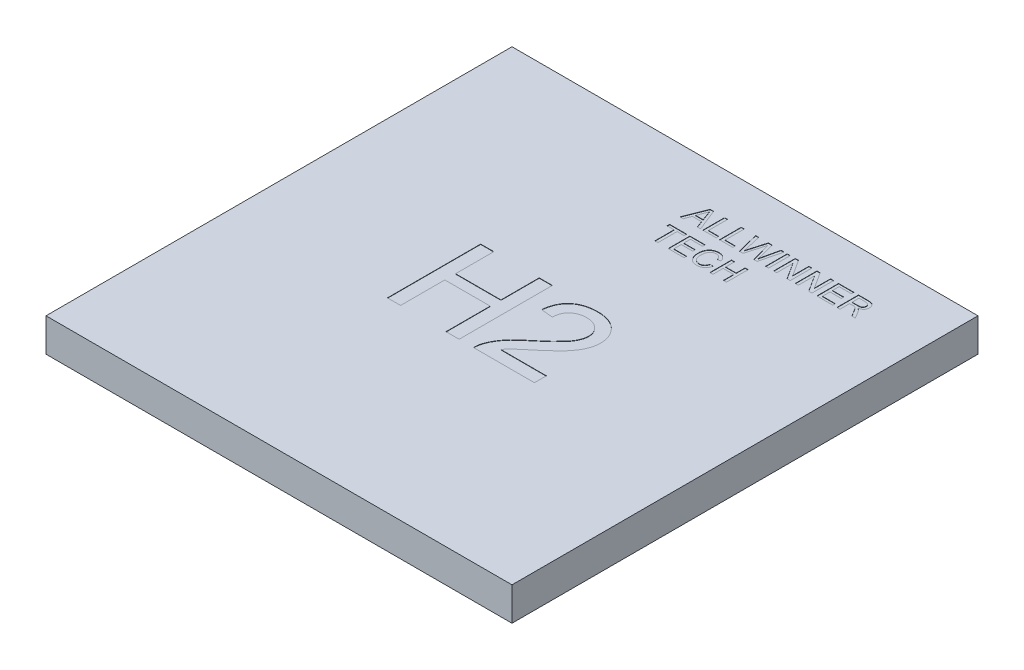
from build123d import *

# Parameters (mm, degrees)
SKETCH_1_W          = 14
SKETCH_1_H          = 14
EXTRUDE_1_DEPTH     = 1
SKETCH_2_W          = 0.091666667
SKETCH_2_H          = 0.65
CUT_EXTRUDE_1_DEPTH = 0.01


with BuildPart() as part:
    # Эскиз1 → Бобышка-Вытянуть1 (new body)
    with BuildSketch(Plane(origin=(0, 0, 0), x_dir=(1, 0, 0), z_dir=(0, 1, 0))):
        Rectangle(SKETCH_1_W, SKETCH_1_H)
    extrude(amount=EXTRUDE_1_DEPTH)

    # Эскиз2 → Вырез-Вытянуть1 (cut)
    with BuildSketch(Plane(origin=(0, 1, 0), x_dir=(1, 0, 0), z_dir=(0, 1, 0))):
        Polygon((-0.049679802, 5.096192526), (0.208393115, 5.746192526), (0.311778531, 5.746192526), (0.569851448, 5.096192526), (0.472585823, 5.096192526), (0.39862749, 5.296192526), (0.121544156, 5.296192526), (0.047585823, 5.096192526), align=None)
        with BuildLine():
            Line((0.149148323, 5.371192526), (0.371023323, 5.371192526))
            Line((0.371023323, 5.371192526), (0.307872281, 5.542025859))
            add(Edge.make_bspline(
                [(0.307872281, 5.542025859), (0.305451296, 5.548626626), (0.300717812, 5.561532372), (0.293658762, 5.580283332), (0.287209727, 5.598090013), (0.280885919, 5.614697093), (0.275177305, 5.630345806), (0.269915528, 5.644930453), (0.264711676, 5.658349663), (0.261588771, 5.667019856), (0.260085823, 5.671192526)],
                knots=[0, 0, 0, 0, 1.225184869, 2.395467751, 3.491410812, 4.525364584, 5.492066482, 6.394148129, 7.227157926, 8, 8, 8, 8], degree=3))
            add(Edge.make_bspline(
                [(0.260085823, 5.671192526), (0.257599656, 5.660903089), (0.252617072, 5.640281791), (0.242184753, 5.610068821), (0.230250543, 5.580132164), (0.220558542, 5.560841186), (0.215684781, 5.551140442)],
                knots=[0, 0, 0, 0, 0.9891762, 1.982431084, 2.985436691, 4, 4, 4, 4], degree=3))
            Line((0.215684781, 5.551140442), (0.149148323, 5.371192526))
        make_face(mode=Mode.SUBTRACT)
        Polygon((0.63925249, 5.096192526), (0.63925249, 5.746192526), (0.730919156, 5.746192526), (0.730919156, 5.171192526), (1.03925249, 5.171192526), (1.03925249, 5.096192526), align=None)
        Polygon((1.13925249, 5.096192526), (1.13925249, 5.746192526), (1.230919156, 5.746192526), (1.230919156, 5.171192526), (1.53925249, 5.171192526), (1.53925249, 5.096192526), align=None)
        with BuildLine():
            Line((1.736257698, 5.096192526), (1.572585823, 5.746192526))
            Line((1.572585823, 5.746192526), (1.667247281, 5.746192526))
            Line((1.667247281, 5.746192526), (1.763731656, 5.318718567))
            add(Edge.make_bspline(
                [(1.763731656, 5.318718567), (1.768732077, 5.296672008), (1.778681867, 5.252803968), (1.788523558, 5.20891155), (1.793419156, 5.187077942)],
                knots=[0, 0, 0, 0, 1.00513078, 2, 2, 2, 2], degree=3))
            add(Edge.make_bspline(
                [(1.793419156, 5.187077942), (1.795737068, 5.194928767), (1.800112864, 5.209749694), (1.806028091, 5.230759787), (1.811400702, 5.249096811), (1.815977892, 5.264846252), (1.819684024, 5.278030236), (1.822883857, 5.28848676), (1.825064823, 5.296420596), (1.826357267, 5.300794547), (1.826882698, 5.302572734)],
                knots=[0, 0, 0, 0, 1.633809233, 3.084334118, 4.356383392, 5.447555203, 6.357852567, 7.089694452, 7.629924063, 8, 8, 8, 8], degree=3))
            Line((1.826882698, 5.302572734), (1.955268115, 5.746192526))
            Line((1.955268115, 5.746192526), (2.065554573, 5.746192526))
            Line((2.065554573, 5.746192526), (2.158393115, 5.420541484))
            add(Edge.make_bspline(
                [(2.158393115, 5.420541484), (2.163516509, 5.40042404), (2.173618735, 5.360756794), (2.187041172, 5.301670961), (2.199429653, 5.244018563), (2.20656565, 5.205887779), (2.210085823, 5.187077942)],
                knots=[0, 0, 0, 0, 1.04154457, 2.053700482, 3.039894486, 4, 4, 4, 4], degree=3))
            add(Edge.make_bspline(
                [(2.210085823, 5.187077942), (2.212243963, 5.196716074), (2.216785556, 5.216998567), (2.224201709, 5.248938702), (2.231877116, 5.284058513), (2.237412503, 5.308479343), (2.240294156, 5.321192526)],
                knots=[0, 0, 0, 0, 0.862130727, 1.814268567, 2.86213528, 4, 4, 4, 4], degree=3))
            Line((2.240294156, 5.321192526), (2.336257698, 5.746192526))
            Line((2.336257698, 5.746192526), (2.430919156, 5.746192526))
            Line((2.430919156, 5.746192526), (2.267117073, 5.096192526))
            Line((2.267117073, 5.096192526), (2.166335823, 5.096192526))
            Line((2.166335823, 5.096192526), (2.030528531, 5.592937317))
            add(Edge.make_bspline(
                [(2.030528531, 5.592937317), (2.02916483, 5.597793459), (2.026574307, 5.607018321), (2.023178737, 5.620182511), (2.019811452, 5.631759874), (2.01713311, 5.64190003), (2.014815229, 5.650500796), (2.012762646, 5.657536991), (2.011442479, 5.663146325), (2.010487796, 5.666334503), (2.010085823, 5.667676901)],
                knots=[0, 0, 0, 0, 1.562239628, 2.967673567, 4.210417925, 5.296319877, 6.215971374, 6.969386481, 7.566055473, 8, 8, 8, 8], degree=3))
            add(Edge.make_bspline(
                [(2.010085823, 5.667676901), (2.00767561, 5.659164066), (2.003121493, 5.643078992), (1.996377055, 5.620434574), (1.990717764, 5.600523267), (1.987131341, 5.588204797), (1.985476448, 5.582520651)],
                knots=[0, 0, 0, 0, 1.197730334, 2.263121701, 3.198547257, 4, 4, 4, 4], degree=3))
            Line((1.985476448, 5.582520651), (1.84472124, 5.096192526))
            Line((1.84472124, 5.096192526), (1.736257698, 5.096192526))
        make_face()
        with Locations((2.568419157, 5.421192526)):
            Rectangle(SKETCH_2_W, SKETCH_2_H)
        Polygon((2.76425249, 5.096192526), (2.76425249, 5.746192526), (2.86112749, 5.746192526), (3.172585823, 5.261166484), (3.172585823, 5.746192526), (3.26425249, 5.746192526), (3.26425249, 5.096192526), (3.16737749, 5.096192526), (2.855919156, 5.581218567), (2.855919156, 5.096192526), align=None)
        Polygon((3.41425249, 5.096192526), (3.41425249, 5.746192526), (3.51112749, 5.746192526), (3.822585823, 5.261166484), (3.822585823, 5.746192526), (3.91425249, 5.746192526), (3.91425249, 5.096192526), (3.81737749, 5.096192526), (3.505919156, 5.581218567), (3.505919156, 5.096192526), align=None)
        Polygon((4.06425249, 5.096192526), (4.06425249, 5.746192526), (4.522585823, 5.746192526), (4.522585823, 5.671192526), (4.155919156, 5.671192526), (4.155919156, 5.471192526), (4.497585823, 5.471192526), (4.497585823, 5.396192526), (4.155919156, 5.396192526), (4.155919156, 5.171192526), (4.53925249, 5.171192526), (4.53925249, 5.096192526), align=None)
        with BuildLine():
            Line((4.66425249, 5.096192526), (4.66425249, 5.746192526))
            Line((4.66425249, 5.746192526), (4.94628374, 5.746192526))
            add(Edge.make_bspline(
                [(4.94628374, 5.746192526), (4.952924712, 5.746140491), (4.965777537, 5.746039784), (4.984416786, 5.745326891), (5.001814657, 5.743790081), (5.018003138, 5.742128236), (5.032979354, 5.739577526), (5.046727852, 5.736651919), (5.059269861, 5.733170402), (5.070661451, 5.729058462), (5.081230362, 5.724406418), (5.091026944, 5.718666547), (5.100458429, 5.712376872), (5.109174781, 5.704987442), (5.117405895, 5.696896701), (5.125144142, 5.687994712), (5.132274963, 5.678204224), (5.141069977, 5.664192006), (5.150505234, 5.645530681), (5.158366285, 5.621648229), (5.16343495, 5.596666313), (5.163977311, 5.579594067), (5.16425249, 5.570932109)],
                knots=[0, 0, 0, 0, 1.242255013, 2.404239178, 3.487702428, 4.508875116, 5.447164253, 6.327763259, 7.137389581, 7.87956647, 8.591787438, 9.293660819, 10.000726923, 10.709654955, 11.427269343, 12.158170644, 12.913245971, 13.690346794, 15.251572448, 16.809945773, 18.381459854, 20, 20, 20, 20], degree=3))
            add(Edge.make_bspline(
                [(5.16425249, 5.570932109), (5.164125296, 5.565371904), (5.16387408, 5.554390119), (5.161949737, 5.538243956), (5.158467796, 5.522816946), (5.154002892, 5.507973982), (5.147891801, 5.493925366), (5.140812367, 5.480384151), (5.132041955, 5.467722349), (5.122222508, 5.455602797), (5.110962237, 5.444285064), (5.098162083, 5.434177466), (5.083948933, 5.425085661), (5.068255848, 5.417260496), (5.051263471, 5.410107924), (5.032758595, 5.404348328), (5.012815903, 5.399645176), (4.998990702, 5.397367728), (4.991856656, 5.396192526)],
                knots=[0, 0, 0, 0, 0.982609109, 1.940720374, 2.867584677, 3.775009516, 4.675469332, 5.571146231, 6.471115823, 7.392408543, 8.32534739, 9.286126426, 10.269214477, 11.301811357, 12.381622301, 13.524260118, 14.722474812, 16, 16, 16, 16], degree=3))
            add(Edge.make_bspline(
                [(4.991856656, 5.396192526), (4.997089749, 5.393548882), (5.007027581, 5.388528509), (5.020786633, 5.380656607), (5.032449705, 5.372613462), (5.039206714, 5.366860769), (5.04237749, 5.364161276)],
                knots=[0, 0, 0, 0, 1.172304973, 2.226249348, 3.167654437, 4, 4, 4, 4], degree=3))
            add(Edge.make_bspline(
                [(5.04237749, 5.364161276), (5.048517877, 5.358141902), (5.061130668, 5.345777681), (5.078511641, 5.32471779), (5.095363092, 5.301274901), (5.10560162, 5.284332645), (5.110867073, 5.275619609)],
                knots=[0, 0, 0, 0, 0.918110279, 1.885863737, 2.912745394, 4, 4, 4, 4], degree=3))
            Line((5.110867073, 5.275619609), (5.217507698, 5.096192526))
            Line((5.217507698, 5.096192526), (5.112429573, 5.096192526))
            Line((5.112429573, 5.096192526), (5.03143999, 5.233432109))
            add(Edge.make_bspline(
                [(5.03143999, 5.233432109), (5.028528011, 5.238247325), (5.022885075, 5.247578422), (5.014734055, 5.261206041), (5.006742248, 5.273752435), (4.999329985, 5.285576188), (4.992196461, 5.296462644), (4.985410605, 5.306449623), (4.979159166, 5.315668138), (4.97141595, 5.32640089), (4.962404133, 5.338276779), (4.95188796, 5.350506702), (4.941873446, 5.360257457), (4.929540388, 5.369819109), (4.914264029, 5.378762427), (4.901278835, 5.382871637), (4.894981656, 5.384864401)],
                knots=[0, 0, 0, 0, 1.130940588, 2.191577161, 3.191089816, 4.120344442, 4.99615009, 5.80661983, 6.546979556, 7.234477901, 8.466216387, 9.541989141, 10.473533583, 11.269175393, 12.675684693, 14, 14, 14, 14], degree=3))
            add(Edge.make_bspline(
                [(4.894981656, 5.384864401), (4.892339593, 5.385340854), (4.886307685, 5.386428612), (4.876065519, 5.387139029), (4.863655879, 5.387893041), (4.854662401, 5.387871072), (4.849799365, 5.387859192)],
                knots=[0, 0, 0, 0, 0.709978628, 1.620902492, 2.713552433, 4, 4, 4, 4], degree=3))
            Line((4.849799365, 5.387859192), (4.755919156, 5.387859192))
            Line((4.755919156, 5.387859192), (4.755919156, 5.096192526))
            Line((4.755919156, 5.096192526), (4.66425249, 5.096192526))
        make_face()
        with BuildLine():
            Line((4.755919156, 5.462859192), (4.930007698, 5.462859192))
            add(Edge.make_bspline(
                [(4.930007698, 5.462859192), (4.938737157, 5.462995773), (4.955056061, 5.463251098), (4.977875468, 5.465431302), (4.99732268, 5.468895741), (5.01378214, 5.47394903), (5.027610685, 5.480964673), (5.039637633, 5.489514544), (5.049632178, 5.500224149), (5.057946608, 5.512307658), (5.064409584, 5.525604956), (5.069071667, 5.539571818), (5.072123082, 5.554090862), (5.07243021, 5.563972322), (5.072585823, 5.568978984)],
                knots=[0, 0, 0, 0, 1.546323217, 2.890706218, 4.056530419, 5.041445823, 5.928701482, 6.793137403, 7.641659452, 8.509781392, 9.383301667, 10.251423607, 11.114044887, 12, 12, 12, 12], degree=3))
            add(Edge.make_bspline(
                [(5.072585823, 5.568978984), (5.07246484, 5.572627528), (5.07222787, 5.579773956), (5.070985596, 5.590262927), (5.06857032, 5.600229873), (5.065380955, 5.609727483), (5.061119315, 5.618686191), (5.056056661, 5.627175418), (5.050015352, 5.635148114), (5.043095379, 5.642628564), (5.035149994, 5.649435043), (5.026074495, 5.655307558), (5.015940462, 5.660297929), (5.004736115, 5.664258621), (4.99249675, 5.667426529), (4.979152691, 5.669534037), (4.964764962, 5.671059022), (4.954795101, 5.671147193), (4.949669156, 5.671192526)],
                knots=[0, 0, 0, 0, 0.965208469, 1.890559848, 2.786986821, 3.67262109, 4.535197034, 5.405224191, 6.282113641, 7.175449223, 8.095446547, 9.040936516, 10.026471658, 11.075712529, 12.17809725, 13.364958037, 14.645208957, 16, 16, 16, 16], degree=3))
            Line((4.949669156, 5.671192526), (4.755919156, 5.671192526))
            Line((4.755919156, 5.671192526), (4.755919156, 5.462859192))
        make_face(mode=Mode.SUBTRACT)
        Polygon((0.197585823, 4.096192526), (0.197585823, 4.671192526), (-0.01074751, 4.671192526), (-0.01074751, 4.746192526), (0.497585823, 4.746192526), (0.497585823, 4.671192526), (0.28925249, 4.671192526), (0.28925249, 4.096192526), align=None)
        Polygon((0.597585823, 4.096192526), (0.597585823, 4.746192526), (1.055919156, 4.746192526), (1.055919156, 4.671192526), (0.68925249, 4.671192526), (0.68925249, 4.471192526), (1.030919156, 4.471192526), (1.030919156, 4.396192526), (0.68925249, 4.396192526), (0.68925249, 4.171192526), (1.072585823, 4.171192526), (1.072585823, 4.096192526), align=None)
        with BuildLine():
            Line((1.63925249, 4.325619609), (1.730919156, 4.304265442))
            add(Edge.make_bspline(
                [(1.730919156, 4.304265442), (1.72862265, 4.29567378), (1.7241304, 4.278867423), (1.715248675, 4.254815665), (1.705280028, 4.232244117), (1.693982574, 4.211212235), (1.681232664, 4.191840939), (1.667368119, 4.173881272), (1.651839784, 4.157709865), (1.635217412, 4.142953489), (1.61737158, 4.129938405), (1.598517446, 4.118699641), (1.578746149, 4.109137734), (1.557977779, 4.101274609), (1.536198871, 4.095356933), (1.513521565, 4.091043785), (1.489879736, 4.088387136), (1.473764655, 4.088037381), (1.465554573, 4.087859192)],
                knots=[0, 0, 0, 0, 1.145254194, 2.240259345, 3.299159039, 4.322497661, 5.312016644, 6.284080175, 7.241264552, 8.196044782, 9.144516039, 10.082428046, 11.020306713, 11.970622414, 12.939253955, 13.924100776, 14.94240044, 16, 16, 16, 16], degree=3))
            add(Edge.make_bspline(
                [(1.465554573, 4.087859192), (1.45713087, 4.087981573), (1.440650568, 4.088221003), (1.416507875, 4.090168456), (1.393545804, 4.093546011), (1.371807235, 4.09823864), (1.351218999, 4.104040785), (1.33186647, 4.111340397), (1.313783544, 4.120084806), (1.296819386, 4.13002946), (1.281046049, 4.141327035), (1.26610484, 4.153672639), (1.252358483, 4.167406134), (1.239463268, 4.18220326), (1.227700056, 4.19825921), (1.216636076, 4.215355858), (1.206811355, 4.233794447), (1.197861796, 4.253233124), (1.190006578, 4.273483688), (1.183057457, 4.294146134), (1.17737617, 4.315261635), (1.172484949, 4.336652507), (1.168931714, 4.35849874), (1.166110556, 4.380636421), (1.164559426, 4.403201271), (1.164355314, 4.418369199), (1.16425249, 4.426010234)],
                knots=[0, 0, 0, 0, 1.180702053, 2.309949215, 3.392367133, 4.431746864, 5.425408375, 6.388154007, 7.326956194, 8.237882283, 9.141054626, 10.043899035, 10.951650021, 11.86168169, 12.792564695, 13.739356664, 14.713891418, 15.718426911, 16.737522708, 17.757217648, 18.772674716, 19.801476837, 20.831699174, 21.873853055, 22.928926693, 24, 24, 24, 24], degree=3))
            add(Edge.make_bspline(
                [(1.16425249, 4.426010234), (1.16439955, 4.434259039), (1.164690104, 4.450556594), (1.166330275, 4.474604111), (1.169342675, 4.497812906), (1.173526023, 4.520198246), (1.178819632, 4.54177826), (1.185353999, 4.562563461), (1.193046464, 4.582527256), (1.201873575, 4.601691658), (1.211893979, 4.619842742), (1.222808608, 4.637006311), (1.234877816, 4.652900548), (1.247743771, 4.667829115), (1.261727808, 4.681543435), (1.276787225, 4.694074575), (1.292792097, 4.705536835), (1.309740088, 4.715823803), (1.327409667, 4.724850079), (1.345538384, 4.732889862), (1.364198346, 4.739479557), (1.38324161, 4.744958624), (1.402709175, 4.74932047), (1.422646529, 4.752237249), (1.44303525, 4.754138049), (1.456782918, 4.754395653), (1.463731656, 4.754525859)],
                knots=[0, 0, 0, 0, 1.185634383, 2.342514083, 3.462112933, 4.547331452, 5.613960142, 6.653690668, 7.676612054, 8.686959706, 9.683658101, 10.654407272, 11.607580201, 12.5494388, 13.484601218, 14.419076806, 15.362504069, 16.311442244, 17.265594461, 18.212500624, 19.159571152, 20.107257795, 21.059246075, 22.024387127, 23.001429356, 24, 24, 24, 24], degree=3))
            add(Edge.make_bspline(
                [(1.463731656, 4.754525859), (1.471506359, 4.75437931), (1.486788306, 4.754091252), (1.509211841, 4.751721926), (1.530687733, 4.747753563), (1.551309041, 4.742547446), (1.570861369, 4.735419188), (1.589556991, 4.726944509), (1.607209922, 4.716763208), (1.623957519, 4.705155087), (1.639527154, 4.692098737), (1.65413671, 4.67790607), (1.667190485, 4.662222374), (1.679205487, 4.645427223), (1.689803686, 4.627287724), (1.699374977, 4.607962034), (1.707606009, 4.58730649), (1.712010021, 4.572919332), (1.71425249, 4.565593567)],
                knots=[0, 0, 0, 0, 1.098391872, 2.158997981, 3.181470371, 4.182549255, 5.160268219, 6.118029851, 7.079534476, 8.035645336, 8.993622929, 9.94770573, 10.909620999, 11.872786677, 12.862530088, 13.874594564, 14.917769567, 16, 16, 16, 16], degree=3))
            Line((1.71425249, 4.565593567), (1.622585823, 4.545932109))
            add(Edge.make_bspline(
                [(1.622585823, 4.545932109), (1.620785633, 4.551554257), (1.617262103, 4.562558541), (1.611005732, 4.578241601), (1.60424906, 4.592800605), (1.596831138, 4.606136587), (1.588735888, 4.618252741), (1.580149724, 4.629296321), (1.57086693, 4.639061198), (1.561076324, 4.647772524), (1.550525086, 4.655193741), (1.539460582, 4.66177016), (1.527649516, 4.667211144), (1.515261801, 4.671813092), (1.502181648, 4.675315671), (1.488462323, 4.677779873), (1.474091772, 4.679206033), (1.464299048, 4.679417835), (1.459304573, 4.679525859)],
                knots=[0, 0, 0, 0, 1.235697765, 2.418642872, 3.532555292, 4.594392283, 5.610119701, 6.580908344, 7.519430642, 8.427315627, 9.319973334, 10.216139639, 11.118687699, 12.038725643, 12.980015607, 13.949697744, 14.954307006, 16, 16, 16, 16], degree=3))
            add(Edge.make_bspline(
                [(1.459304573, 4.679525859), (1.453570459, 4.679442663), (1.442293149, 4.67927904), (1.425725424, 4.677488209), (1.409814646, 4.67485049), (1.394679397, 4.670895004), (1.380236855, 4.665963541), (1.366572726, 4.659822997), (1.353570776, 4.652625559), (1.341376113, 4.644328005), (1.330091224, 4.634999959), (1.319409868, 4.625138754), (1.309844868, 4.614284487), (1.301031484, 4.602795066), (1.293226361, 4.590467464), (1.286200442, 4.577469599), (1.279998513, 4.563694942), (1.273237989, 4.544308157), (1.266344729, 4.519338425), (1.260364817, 4.488783567), (1.256555754, 4.457747318), (1.256131804, 4.436871772), (1.255919156, 4.426400859)],
                knots=[0, 0, 0, 0, 0.935256702, 1.839373932, 2.716087708, 3.564631604, 4.388828665, 5.203538865, 6.005592122, 6.810952829, 7.606223804, 8.392839071, 9.180346482, 9.963639178, 10.753404291, 11.558266631, 12.372976832, 13.215232055, 14.905983541, 16.594894834, 18.292041732, 20, 20, 20, 20], degree=3))
            add(Edge.make_bspline(
                [(1.255919156, 4.426400859), (1.256158993, 4.413235437), (1.256624298, 4.387693328), (1.261215717, 4.350678592), (1.268215965, 4.316153806), (1.276664255, 4.289217594), (1.28513874, 4.269348938), (1.291992477, 4.255434631), (1.299815744, 4.242559006), (1.308413949, 4.230648941), (1.317897844, 4.219739178), (1.328135301, 4.209771763), (1.339128606, 4.200650786), (1.351008019, 4.192803216), (1.363316287, 4.185835258), (1.37589809, 4.179639217), (1.388761349, 4.17439888), (1.401957962, 4.17032808), (1.415302613, 4.166810342), (1.428942279, 4.164512391), (1.442873072, 4.1632155), (1.452227255, 4.162978914), (1.456960823, 4.162859192)],
                knots=[0, 0, 0, 0, 2.10686522, 4.087509323, 5.961373225, 7.741398778, 8.594514555, 9.418024779, 10.222433421, 11.003575649, 11.767087398, 12.533660211, 13.289033706, 14.050297079, 14.809623433, 15.552362432, 16.294320901, 17.0305302, 17.761969017, 18.502233515, 19.242073914, 20, 20, 20, 20], degree=3))
            add(Edge.make_bspline(
                [(1.456960823, 4.162859192), (1.462609688, 4.162977661), (1.473768194, 4.163211678), (1.49012798, 4.165260045), (1.505898589, 4.168278582), (1.520888961, 4.172936488), (1.535300734, 4.17863955), (1.549015828, 4.185672421), (1.561991112, 4.194130914), (1.574379202, 4.203734737), (1.585951652, 4.214662247), (1.596557181, 4.226825405), (1.606071538, 4.240279663), (1.614893742, 4.2548091), (1.622306014, 4.270847761), (1.629171528, 4.287917607), (1.634892371, 4.306299195), (1.637778239, 4.319086958), (1.63925249, 4.325619609)],
                knots=[0, 0, 0, 0, 1.013374089, 2.001772144, 2.95501459, 3.891367103, 4.814208647, 5.733921849, 6.652182523, 7.590185968, 8.54346024, 9.504121027, 10.481158517, 11.497760682, 12.549996529, 13.647863555, 14.798406869, 16, 16, 16, 16], degree=3))
        make_face()
        Polygon((1.847585823, 4.096192526), (1.847585823, 4.746192526), (1.93925249, 4.746192526), (1.93925249, 4.479525859), (2.255919156, 4.479525859), (2.255919156, 4.746192526), (2.347585823, 4.746192526), (2.347585823, 4.096192526), (2.255919156, 4.096192526), (2.255919156, 4.404525859), (1.93925249, 4.404525859), (1.93925249, 4.096192526), align=None)
        Polygon((-2.336984878, -1.40444844), (-2.336984878, 1.39555156), (-1.942113084, 1.39555156), (-1.942113084, 0.246833611), (-0.578010519, 0.246833611), (-0.578010519, 1.39555156), (-0.183138725, 1.39555156), (-0.183138725, -1.40444844), (-0.578010519, -1.40444844), (-0.578010519, -0.076243312), (-1.942113084, -0.076243312), (-1.942113084, -1.40444844), align=None)
        with BuildLine():
            Line((2.078399737, -1.045474081), (2.078399737, -1.40444844))
            Line((2.078399737, -1.40444844), (0.247630506, -1.40444844))
            add(Edge.make_bspline(
                [(0.247630506, -1.40444844), (0.247593025, -1.383113585), (0.24751819, -1.340515384), (0.254726492, -1.277515346), (0.266016135, -1.215351058), (0.278781332, -1.175487571), (0.285210634, -1.155409979)],
                knots=[0, 0, 0, 0, 1.01057331, 2.01775941, 3.001627217, 4, 4, 4, 4], degree=3))
            add(Edge.make_bspline(
                [(0.285210634, -1.155409979), (0.297089847, -1.122605587), (0.321277879, -1.055810443), (0.370283086, -0.959434379), (0.42792479, -0.863641178), (0.484047103, -0.785651987), (0.535443023, -0.723344077), (0.578545201, -0.674595347), (0.626310315, -0.624695278), (0.678700114, -0.573652985), (0.735210376, -0.521137886), (0.79591821, -0.466974846), (0.86154048, -0.412173253), (0.907351693, -0.375848477), (0.930803583, -0.357252927)],
                knots=[0, 0, 0, 0, 1.204657718, 2.452881516, 3.728232997, 5.065887527, 5.768225529, 6.518857853, 7.313994055, 8.154655305, 9.046094665, 9.979688118, 10.965752482, 12, 12, 12, 12], degree=3))
            add(Edge.make_bspline(
                [(0.930803583, -0.357252927), (0.96683148, -0.326928832), (1.036205479, -0.268537862), (1.134172438, -0.181891075), (1.223649309, -0.101434626), (1.303211274, -0.02575835), (1.373509066, 0.044403742), (1.434707745, 0.108892687), (1.487333885, 0.167507229), (1.530745023, 0.222368967), (1.567372332, 0.274173707), (1.598410742, 0.324706032), (1.624277138, 0.374848631), (1.645820385, 0.424442839), (1.662859263, 0.473700742), (1.674473682, 0.522765852), (1.682350179, 0.571151323), (1.683138229, 0.603347553), (1.683527942, 0.619269509)],
                knots=[0, 0, 0, 0, 1.782554561, 3.432421876, 4.950675607, 6.337395053, 7.588547463, 8.709982106, 9.702713005, 10.569305638, 11.356701089, 12.103210377, 12.812277205, 13.490692607, 14.148717897, 14.782152033, 15.397739362, 16, 16, 16, 16], degree=3))
            add(Edge.make_bspline(
                [(1.683527942, 0.619269509), (1.683138182, 0.635005691), (1.682373494, 0.665879225), (1.675118171, 0.711062449), (1.66501818, 0.754574973), (1.648689567, 0.795633477), (1.629253604, 0.835453863), (1.604322289, 0.872777856), (1.575481882, 0.908535666), (1.542462058, 0.941784529), (1.506396678, 0.97297727), (1.466098754, 0.998906016), (1.424215045, 1.022249613), (1.379300596, 1.041019203), (1.331428393, 1.054802049), (1.280946921, 1.064804845), (1.227864192, 1.071147154), (1.191638961, 1.072025434), (1.173111275, 1.072474637)],
                knots=[0, 0, 0, 0, 0.988194508, 1.938783882, 2.870742509, 3.789494954, 4.709148727, 5.651055405, 6.603531303, 7.592354411, 8.592907906, 9.593461401, 10.59787167, 11.603930315, 12.645063138, 13.723588815, 14.835711238, 16, 16, 16, 16], degree=3))
            add(Edge.make_bspline(
                [(1.173111275, 1.072474637), (1.153648457, 1.072027658), (1.115558292, 1.071152888), (1.059880671, 1.064785285), (1.00702442, 1.055056449), (0.957115701, 1.04018189), (0.910215257, 1.021443598), (0.866514104, 0.99785708), (0.825312405, 0.971232166), (0.787907759, 0.939710277), (0.754083229, 0.904758933), (0.72405492, 0.86670749), (0.699451233, 0.824821638), (0.679132494, 0.78002235), (0.662794527, 0.732168795), (0.650933718, 0.680895143), (0.644467126, 0.626349439), (0.643166749, 0.588996555), (0.642502301, 0.569910534)],
                knots=[0, 0, 0, 0, 1.131143733, 2.213731411, 3.253917892, 4.251203413, 5.236093891, 6.184197493, 7.13373276, 8.082770301, 9.020476205, 9.957489029, 10.893177274, 11.836722509, 12.812818608, 13.827831385, 14.890097571, 16, 16, 16, 16], degree=3))
            Line((0.642502301, 0.569910534), (0.283527942, 0.60580797))
            add(Edge.make_bspline(
                [(0.283527942, 0.60580797), (0.28720076, 0.637093463), (0.29434591, 0.697956696), (0.312143506, 0.786106837), (0.337129719, 0.868111736), (0.367027832, 0.945114714), (0.404507934, 1.015804948), (0.446875963, 1.081644586), (0.496847098, 1.140545471), (0.552051944, 1.194364244), (0.613095332, 1.241792744), (0.679403852, 1.283228124), (0.750947173, 1.31788626), (0.827326824, 1.346581752), (0.908718153, 1.368353744), (0.99500602, 1.383966317), (1.086329189, 1.393590085), (1.148968863, 1.394888406), (1.180963839, 1.39555156)],
                knots=[0, 0, 0, 0, 1.130804643, 2.199883102, 3.223565206, 4.205909148, 5.160801384, 6.091796021, 7.01151579, 7.927798993, 8.855738875, 9.7815393, 10.730299821, 11.705391175, 12.706931101, 13.751121791, 14.851322166, 16, 16, 16, 16], degree=3))
            add(Edge.make_bspline(
                [(1.180963839, 1.39555156), (1.213341778, 1.394997124), (1.276414193, 1.393917081), (1.368320839, 1.382866067), (1.455037299, 1.365654213), (1.536881474, 1.341666158), (1.613369818, 1.310210664), (1.684561166, 1.271779155), (1.750783768, 1.226746516), (1.81093118, 1.174572162), (1.865167674, 1.117615115), (1.912697963, 1.056829667), (1.952435573, 0.992475495), (1.986269681, 0.925429791), (2.011365687, 0.854275922), (2.029013661, 0.779981241), (2.041005972, 0.702482258), (2.041996894, 0.649604525), (2.042502301, 0.622634893)],
                knots=[0, 0, 0, 0, 1.195390245, 2.328627238, 3.413424916, 4.457841177, 5.473507151, 6.462241215, 7.441013641, 8.425227782, 9.397253344, 10.342087291, 11.269524934, 12.186751184, 13.110685745, 14.048630397, 15.004728144, 16, 16, 16, 16], degree=3))
            add(Edge.make_bspline(
                [(2.042502301, 0.622634893), (2.041730552, 0.594926652), (2.040185351, 0.539449024), (2.028124851, 0.45652633), (2.007489202, 0.374503532), (1.980131838, 0.292382363), (1.942755985, 0.209836887), (1.895537941, 0.125728389), (1.836958798, 0.039746177), (1.780622087, -0.033348255), (1.728181752, -0.094619822), (1.681698352, -0.145049901), (1.627919747, -0.198628488), (1.568863376, -0.257211133), (1.502120635, -0.318718615), (1.429609198, -0.384992812), (1.349741756, -0.454289639), (1.294298186, -0.501629904), (1.265659352, -0.526083056)],
                knots=[0, 0, 0, 0, 0.927118007, 1.856282007, 2.79721255, 3.754929441, 4.749232485, 5.824981375, 6.979078785, 8.228161913, 8.911614355, 9.677694854, 10.522803217, 11.452009355, 12.461436787, 13.560019032, 14.739651695, 16, 16, 16, 16], degree=3))
            add(Edge.make_bspline(
                [(1.265659352, -0.526083056), (1.241134517, -0.546048886), (1.194369431, -0.584120651), (1.127837036, -0.639314309), (1.068244246, -0.689925399), (1.014197494, -0.734303081), (0.967665127, -0.774593849), (0.927008107, -0.809033144), (0.893703527, -0.83935256), (0.842986547, -0.885408365), (0.778749165, -0.951056259), (0.731416314, -1.014844484), (0.708688198, -1.045474081)],
                knots=[0, 0, 0, 0, 1.241996727, 2.368296581, 3.394949853, 4.3125351, 5.114548721, 5.812230366, 6.404953749, 6.883082049, 8.503329734, 10, 10, 10, 10], degree=3))
            Line((0.708688198, -1.045474081), (2.078399737, -1.045474081))
        make_face()
    extrude(amount=-CUT_EXTRUDE_1_DEPTH, mode=Mode.SUBTRACT)


solid = part.part
